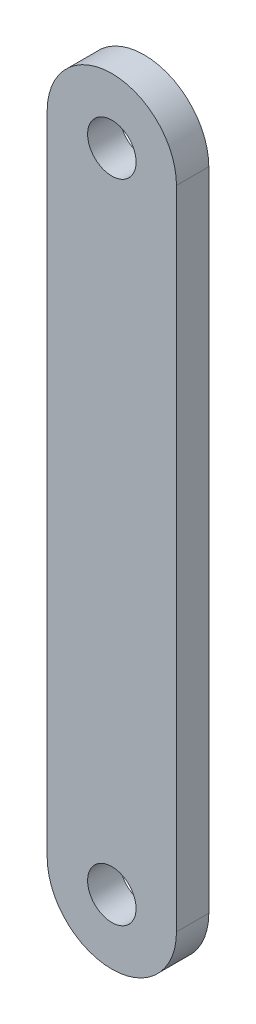
from build123d import *

# Parameters (mm, degrees)
SKETCH1_R           = 1.5
BOSS_EXTRUDE1_DEPTH = 2


with BuildPart() as part:
    # Sketch1 → Boss-Extrude1 (new body)
    with BuildSketch(Plane.XY):
        with BuildLine():
            Line((-4, 24.5), (-4, -15.5))
            ThreePointArc((-4, -15.5), (0, -19.5), (4, -15.5))
            Line((4, -15.5), (4, 24.5))
            ThreePointArc((4, 24.5), (0, 28.5), (-4, 24.5))
        make_face()
        with Locations((0, 24.5)):
            Circle(SKETCH1_R, mode=Mode.SUBTRACT)
        with Locations((0, -15.5)):
            Circle(SKETCH1_R, mode=Mode.SUBTRACT)
    extrude(amount=BOSS_EXTRUDE1_DEPTH)


solid = part.part
